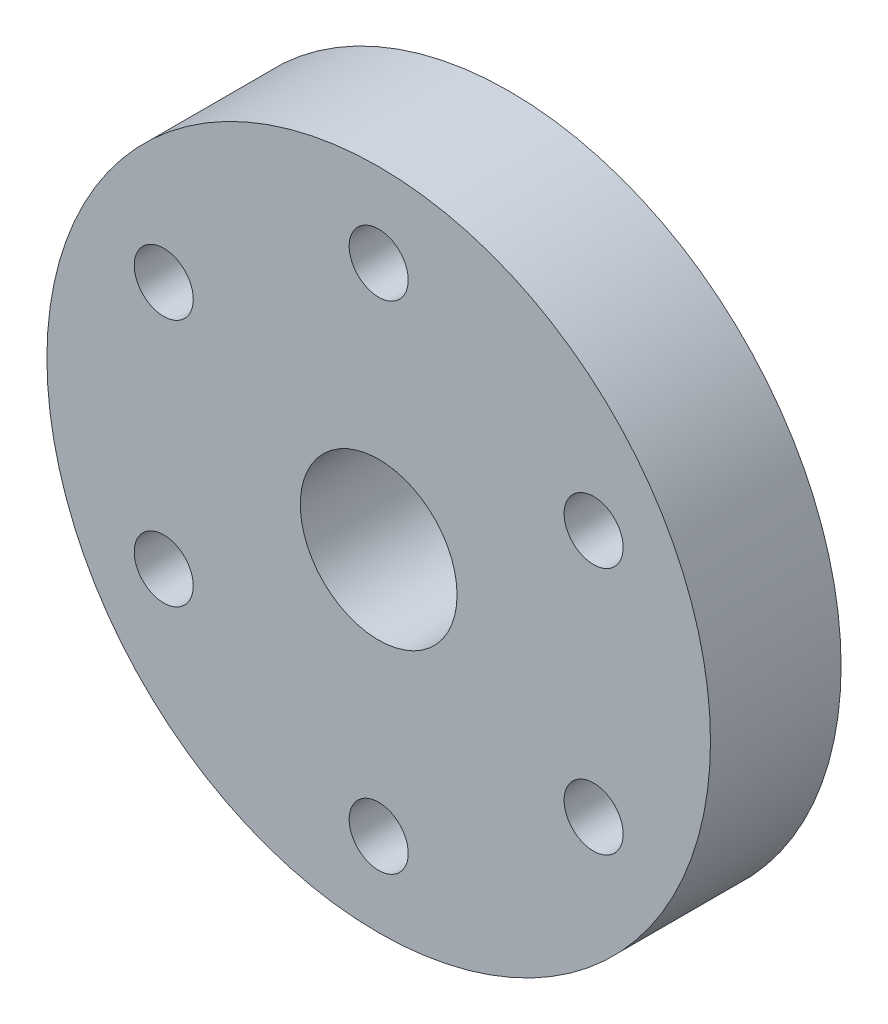
from build123d import *

# Parameters (mm, degrees)
SKETCH1_R                 = 6
SKETCH1_R_2               = 3
BOSS_EXTRUDE1_DEPTH       = 4.2
SKETCH2_R                 = 12.7
SKETCH2_R_2               = 3
BOSS_EXTRUDE2_DEPTH       = 5
SKETCH3_R                 = 1.4
CUT_EXTRUDE1_DEPTH        = 13.7
F_4_40_TAPPED_HOLE1_D     = 2.2606
F_4_40_TAPPED_HOLE1_DEPTH = 7.6
F_4_40_TAPPED_HOLE1_TIP   = 0.679152758


with BuildPart() as part:
    # Sketch1 → Boss-Extrude1 (new body)
    with BuildSketch(Plane.XY):
        Circle(SKETCH1_R)
        Circle(SKETCH1_R_2, mode=Mode.SUBTRACT)
    extrude(amount=BOSS_EXTRUDE1_DEPTH)

    # Sketch2 → Boss-Extrude2 (add)
    with BuildSketch(Plane.XY.offset(4.2)):
        Circle(SKETCH2_R)
        Circle(SKETCH2_R_2, mode=Mode.SUBTRACT)
    extrude(amount=BOSS_EXTRUDE2_DEPTH)

    # Sketch3 → Cut-Extrude1 (cut, through all)
    with BuildSketch(Plane(origin=(0, 0, 0), x_dir=(1, 0, 0), z_dir=(0, 1, 0))):
        with Locations((0, -2.1)):
            Circle(SKETCH3_R)
    extrude(amount=-CUT_EXTRUDE1_DEPTH, mode=Mode.SUBTRACT)

    # #4-40 Tapped Hole1
    with Locations(Plane.XY.offset(9.2)):
        with Locations((-8.227241336, -4.75), (-8.227241336, 4.75), (0, 9.5), (8.227241336, 4.75), (8.227241336, -4.75), (0, -9.5)):
            Hole(F_4_40_TAPPED_HOLE1_D / 2, depth=F_4_40_TAPPED_HOLE1_DEPTH)
            with Locations((0, 0, -(F_4_40_TAPPED_HOLE1_DEPTH + F_4_40_TAPPED_HOLE1_TIP / 2))):  # 118° drill point
                Cone(0, F_4_40_TAPPED_HOLE1_D / 2, F_4_40_TAPPED_HOLE1_TIP, mode=Mode.SUBTRACT)


solid = part.part
